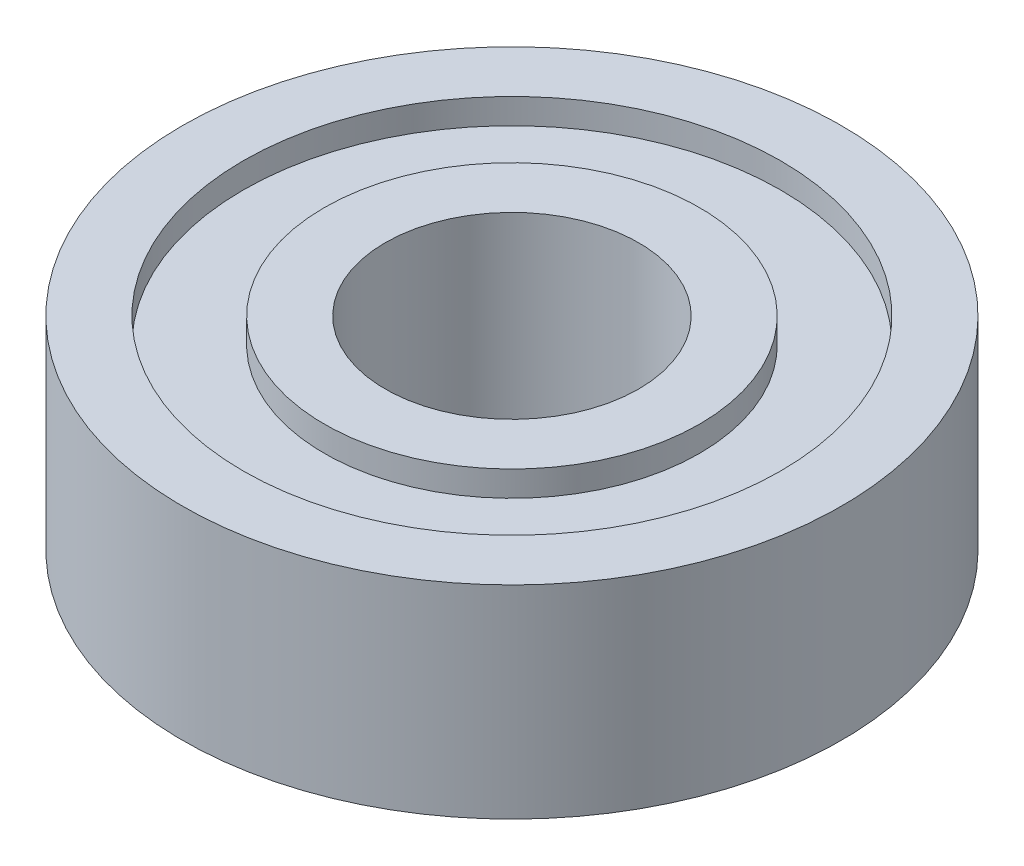
from build123d import *


with BuildPart() as part:
    # Croquis1 → Revolución1 (revolve)
    with BuildSketch(Plane.XY):
        Polygon((-6.5, 2), (-5.3, 2), (-5.3, 1.5), (-3.7, 1.5), (-3.7, 2), (-2.5, 2), (-2.5, -2), (-3.7, -2), (-3.7, -1.5), (-5.3, -1.5), (-5.3, -2), (-6.5, -2), align=None)
    revolve(axis=Axis((0, 40.473679997, 0), (0, -1, 0)))


solid = part.part
